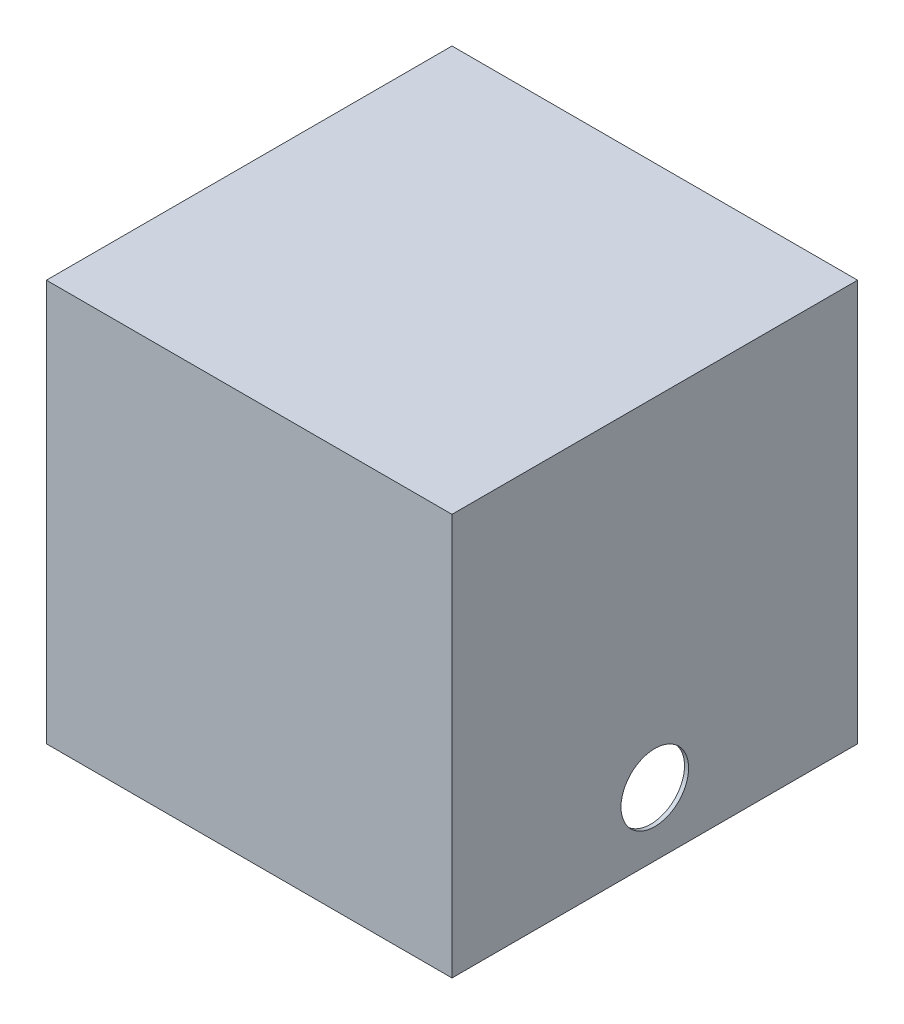
from build123d import *

# Parameters (mm, degrees)
SKETCH1_W               = 300
SKETCH1_H               = 300
BOSS_EXTRUDE1_DEPTH     = 3
SKETCH2_W               = 300
SKETCH2_H               = 300
SKETCH2_W_2             = 294
SKETCH2_H_2             = 294
BOSS_EXTRUDE2_DEPTH     = 297
SKETCH3_W               = 300
SKETCH3_H               = 300
BOSS_EXTRUDE3_DEPTH     = 3
SKETCH4_R               = 25
CUT_EXTRUDE1_DEPTH      = 1
CUT_EXTRUDE1_DEPTH_BACK = 301
SKETCH5_W               = 300
SKETCH5_H               = 300
CUT_EXTRUDE2_DEPTH      = 3


with BuildPart() as part:
    # Sketch1 → Boss-Extrude1 (new body)
    with BuildSketch(Plane(origin=(0, 0, 0), x_dir=(1, 0, 0), z_dir=(0, 1, 0))):
        Rectangle(SKETCH1_W, SKETCH1_H)
    extrude(amount=BOSS_EXTRUDE1_DEPTH)

    # Sketch2 → Boss-Extrude2 (add)
    with BuildSketch(Plane(origin=(0, 3, 0), x_dir=(1, 0, 0), z_dir=(0, 1, 0))):
        Rectangle(SKETCH2_W, SKETCH2_H)
        Rectangle(SKETCH2_W_2, SKETCH2_H_2, mode=Mode.SUBTRACT)
    extrude(amount=BOSS_EXTRUDE2_DEPTH)

    # Sketch3 → Boss-Extrude3 (add)
    with BuildSketch(Plane(origin=(0, 300, 0), x_dir=(1, 0, 0), z_dir=(0, 1, 0))):
        Rectangle(SKETCH3_W, SKETCH3_H)
    extrude(amount=-BOSS_EXTRUDE3_DEPTH)

    # Sketch4 → Cut-Extrude1 (cut, two sides)
    with BuildSketch(Plane(origin=(150, 0, 0), x_dir=(0, 0, -1), z_dir=(1, 0, 0))) as cut_extrude1_sk:
        with Locations((0, 50)):
            Circle(SKETCH4_R)
    extrude(amount=CUT_EXTRUDE1_DEPTH, mode=Mode.SUBTRACT)
    extrude(cut_extrude1_sk.sketch, amount=-CUT_EXTRUDE1_DEPTH_BACK, mode=Mode.SUBTRACT)

    # Sketch5 → Cut-Extrude2 (cut)
    with BuildSketch(Plane.XZ):
        Rectangle(SKETCH5_W, SKETCH5_H)
    extrude(amount=-CUT_EXTRUDE2_DEPTH, mode=Mode.SUBTRACT)


solid = part.part
